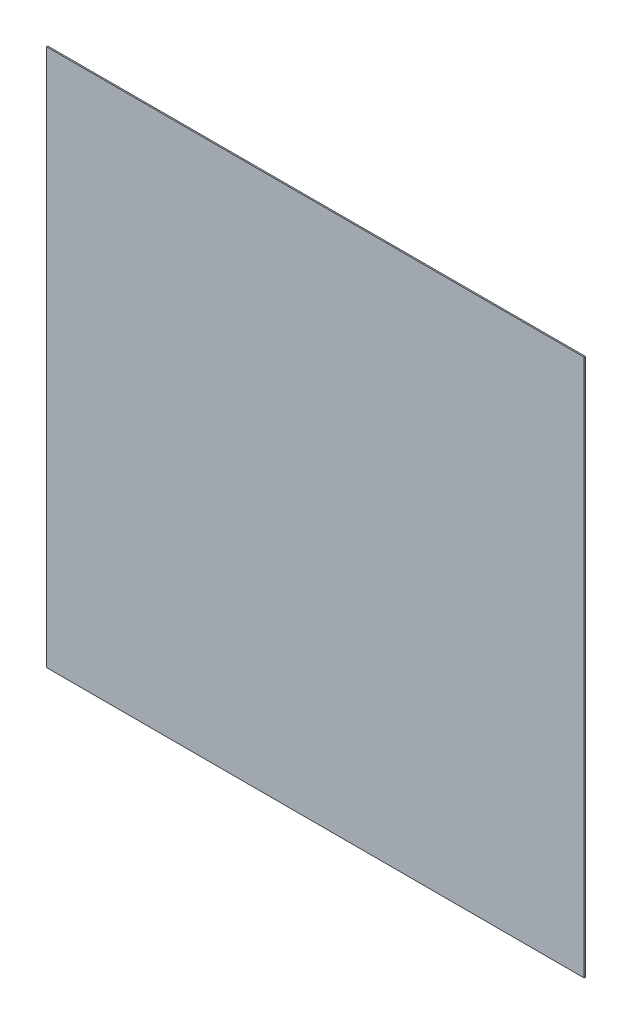
from build123d import *

# Parameters (mm, degrees)
SKETCH1_W           = 626
SKETCH1_H           = 626
BOSS_EXTRUDE1_DEPTH = 1.5
SKETCH2_R           = 5
BOSS_EXTRUDE2_DEPTH = 1.5


with BuildPart() as part:
    # Sketch1 → Boss-Extrude1 (new body)
    with BuildSketch(Plane.XY):
        Rectangle(SKETCH1_W, SKETCH1_H)
    extrude(amount=BOSS_EXTRUDE1_DEPTH)

    # Sketch2 → Boss-Extrude2 (add)
    with BuildSketch(Plane(origin=(0, 0, 0), x_dir=(-1, 0, 0), z_dir=(0, 0, -1))):
        with Locations((0, 293)):
            Circle(SKETCH2_R)
        with Locations((-293, 0)):
            Circle(SKETCH2_R)
        with Locations((0, -293)):
            Circle(SKETCH2_R)
        with Locations((293, 0)):
            Circle(SKETCH2_R)
    extrude(amount=BOSS_EXTRUDE2_DEPTH)


solid = part.part
